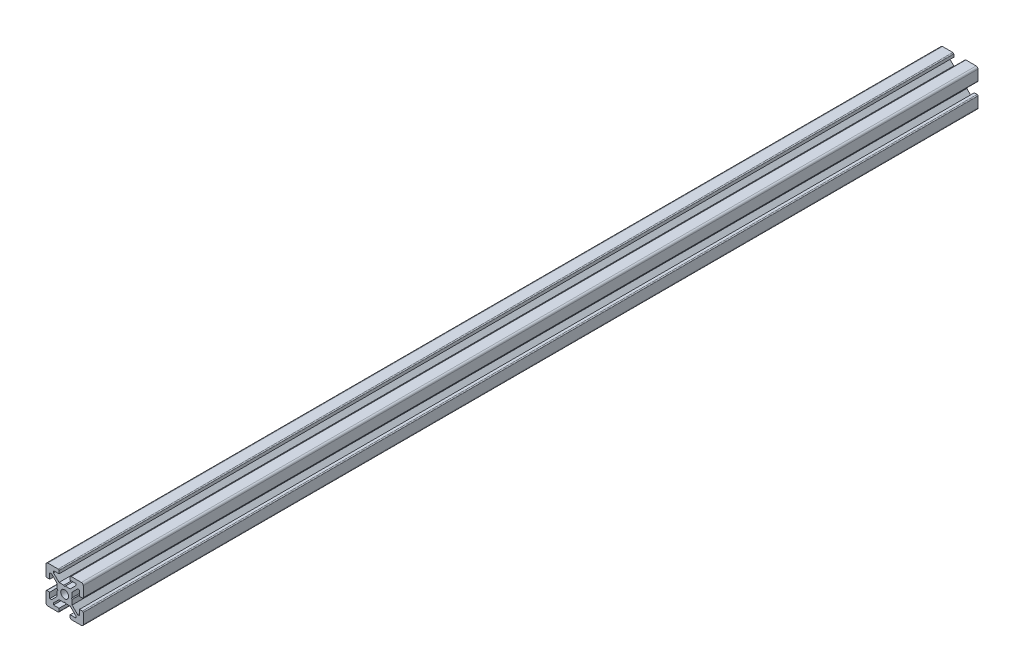
from build123d import *

# Parameters (mm, degrees)
SCHIZZO1_R                   = 2.1
ESTRUSIONE_ESTRUSIONE1_DEPTH = 480


with BuildPart() as part:
    # Schizzo1 → Estrusione-Estrusione1 (new body)
    with BuildSketch(Plane.XY):
        with BuildLine():
            Line((-3.6, 0), (-4, 0.4))
            Line((-4, 0.4), (-4, 3))
            Line((-4, 3), (-7, 6))
            Line((-7, 6), (-8, 6))
            Line((-8, 6), (-8, 3))
            Line((-8, 3), (-9.5, 3))
            ThreePointArc((-9.5, 3), (-9.853553391, 3.146446609), (-10, 3.5))
            Line((-10, 3.5), (-10, 9))
            ThreePointArc((-10, 9), (-9.707106781, 9.707106781), (-9, 10))
            Line((-9, 10), (-3.5, 10))
            ThreePointArc((-3.5, 10), (-3.146446609, 9.853553391), (-3, 9.5))
            Line((-3, 9.5), (-3, 8))
            Line((-3, 8), (-6, 8))
            Line((-6, 8), (-6, 7))
            Line((-6, 7), (-3, 4))
            Line((-3, 4), (-0.4, 4))
            Line((-0.4, 4), (0, 3.6))
            Line((0, 3.6), (0.4, 4))
            Line((0.4, 4), (3, 4))
            Line((3, 4), (6, 7))
            Line((6, 7), (6, 8))
            Line((6, 8), (3, 8))
            Line((3, 8), (3, 9.5))
            ThreePointArc((3, 9.5), (3.146446609, 9.853553391), (3.5, 10))
            Line((3.5, 10), (9, 10))
            ThreePointArc((9, 10), (9.707106781, 9.707106781), (10, 9))
            Line((10, 9), (10, 3.5))
            ThreePointArc((10, 3.5), (9.853553391, 3.146446609), (9.5, 3))
            Line((9.5, 3), (8, 3))
            Line((8, 3), (8, 6))
            Line((8, 6), (7, 6))
            Line((7, 6), (4, 3))
            Line((4, 3), (4, 0.4))
            Line((4, 0.4), (3.6, 0))
            Line((3.6, 0), (4, -0.4))
            Line((4, -0.4), (4, -3))
            Line((4, -3), (7, -6))
            Line((7, -6), (8, -6))
            Line((8, -6), (8, -3))
            Line((8, -3), (9.5, -3))
            ThreePointArc((9.5, -3), (9.853553391, -3.146446609), (10, -3.5))
            Line((10, -3.5), (10, -9))
            ThreePointArc((10, -9), (9.707106781, -9.707106781), (9, -10))
            Line((9, -10), (3.5, -10))
            ThreePointArc((3.5, -10), (3.146446609, -9.853553391), (3, -9.5))
            Line((3, -9.5), (3, -8))
            Line((3, -8), (6, -8))
            Line((6, -8), (6, -7))
            Line((6, -7), (3, -4))
            Line((3, -4), (0.4, -4))
            Line((0.4, -4), (0, -3.6))
            Line((0, -3.6), (-0.4, -4))
            Line((-0.4, -4), (-3, -4))
            Line((-3, -4), (-6, -7))
            Line((-6, -7), (-6, -8))
            Line((-6, -8), (-3, -8))
            Line((-3, -8), (-3, -9.5))
            ThreePointArc((-3, -9.5), (-3.146446609, -9.853553391), (-3.5, -10))
            Line((-3.5, -10), (-9, -10))
            ThreePointArc((-9, -10), (-9.707106781, -9.707106781), (-10, -9))
            Line((-10, -9), (-10, -3.5))
            ThreePointArc((-10, -3.5), (-9.853553391, -3.146446609), (-9.5, -3))
            Line((-9.5, -3), (-8, -3))
            Line((-8, -3), (-8, -6))
            Line((-8, -6), (-7, -6))
            Line((-7, -6), (-4, -3))
            Line((-4, -3), (-4, -0.4))
            Line((-4, -0.4), (-3.6, 0))
        make_face()
        Circle(SCHIZZO1_R, mode=Mode.SUBTRACT)
    extrude(amount=ESTRUSIONE_ESTRUSIONE1_DEPTH)


solid = part.part
